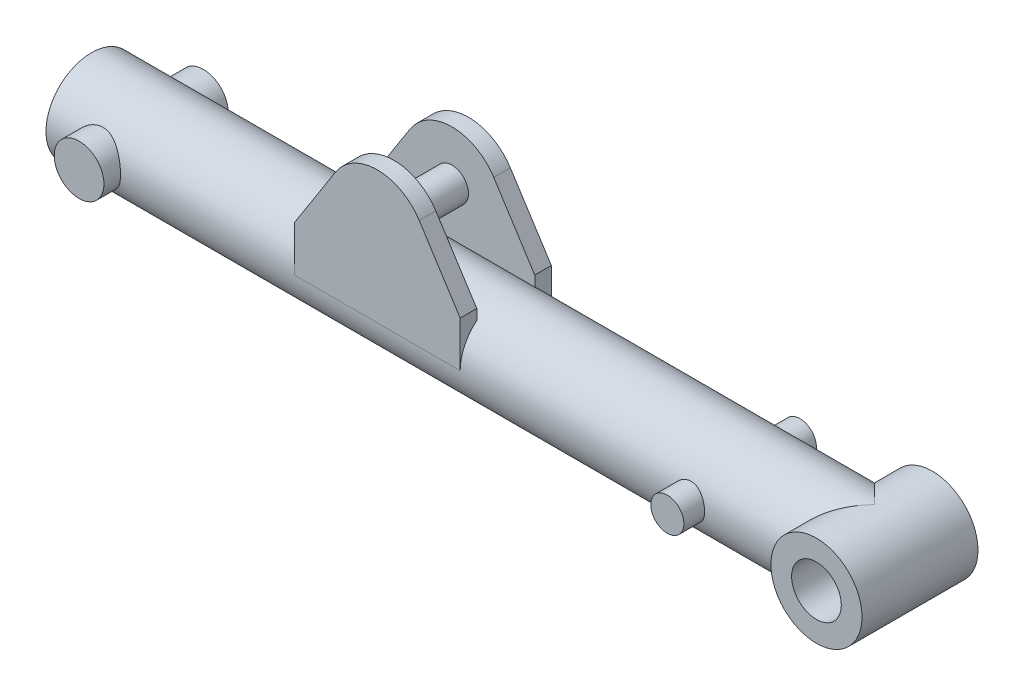
from build123d import *

# Parameters (mm, degrees)
SKETCH1_R           = 55
BOSS_EXTRUDE1_DEPTH = 1000
SHELL1_T            = 10
BOSS_EXTRUDE2_DEPTH = 20
SKETCH5_R           = 55
BOSS_EXTRUDE3_DEPTH = 70
SKETCH6_R           = 30
CUT_EXTRUDE2_DEPTH  = 141
SKETCH2_R           = 30
BOSS_EXTRUDE4_DEPTH = 75
SKETCH7_R           = 20
BOSS_EXTRUDE5_DEPTH = 55
SKETCH8_R           = 20
BOSS_EXTRUDE6_DEPTH = 80


with BuildPart() as part:
    # Sketch1 → Boss-Extrude1 (new body)
    with BuildSketch(Plane(origin=(0, 0, 0), x_dir=(0, 0, -1), z_dir=(1, 0, 0))):
        Circle(SKETCH1_R)
    extrude(amount=BOSS_EXTRUDE1_DEPTH)

    # Shell1 (no face opened: a closed hollow body)
    add(offset(amount=-SHELL1_T, mode=Mode.PRIVATE), mode=Mode.SUBTRACT)


with BuildPart() as body_2:
    # Sketch3 → Boss-Extrude2 (new body)
    with BuildSketch(Plane.XY.offset(55)):
        with BuildLine():
            Line((300, 0), (300, 55))
            Line((300, 55), (349.453051, 132.326552))
            ThreePointArc((349.453051, 132.326552), (400, 160), (450.546949, 132.326552))
            Line((450.546949, 132.326552), (500, 55))
            Line((500, 55), (500, 0))
            Line((500, 0), (300, 0))
        make_face()
    boss_extrude2 = extrude(amount=-BOSS_EXTRUDE2_DEPTH)


with BuildPart() as part_1:
    add(part.part)

    # Mirror2: Boss-Extrude2 across plane
    add(boss_extrude2.mirror(Plane.XY))

    # Sketch5 → Boss-Extrude3 (add, symmetric)
    with BuildSketch(Plane.XY):
        with Locations((945, 0)):
            Circle(SKETCH5_R)
    extrude(amount=BOSS_EXTRUDE3_DEPTH, both=True)

    # Sketch6 → Cut-Extrude2 (cut, through all)
    with BuildSketch(Plane.XY.offset(70)):
        with Locations((945, 0)):
            Circle(SKETCH6_R)
        with BuildLine():
            Line((1000, 0), (1000, 55))
            Line((1000, 55), (945, 55))
            ThreePointArc((945, 55), (983.890873, 38.890873), (1000, 0))
        make_face()
        with BuildLine():
            Line((1000, -55), (1000, 0))
            ThreePointArc((1000, 0), (983.890873, -38.890873), (945, -55))
            Line((945, -55), (1000, -55))
        make_face()
    extrude(amount=-CUT_EXTRUDE2_DEPTH, mode=Mode.SUBTRACT)

    # Sketch2 → Boss-Extrude4 (add, symmetric)
    with BuildSketch(Plane.XY):
        with Locations((60, 0)):
            Circle(SKETCH2_R)
    extrude(amount=BOSS_EXTRUDE4_DEPTH, both=True)

    add(body_2.part)  # Boss-Extrude5 merges body 2
    # Sketch7 → Boss-Extrude5 (add, symmetric)
    with BuildSketch(Plane.XY):
        with Locations((400, 100)):
            Circle(SKETCH7_R)
    extrude(amount=BOSS_EXTRUDE5_DEPTH, both=True)

    # Sketch8 → Boss-Extrude6 (add, symmetric)
    with BuildSketch(Plane.XY):
        with Locations((775, 0)):
            Circle(SKETCH8_R)
    extrude(amount=BOSS_EXTRUDE6_DEPTH, both=True)


solid = part_1.part
